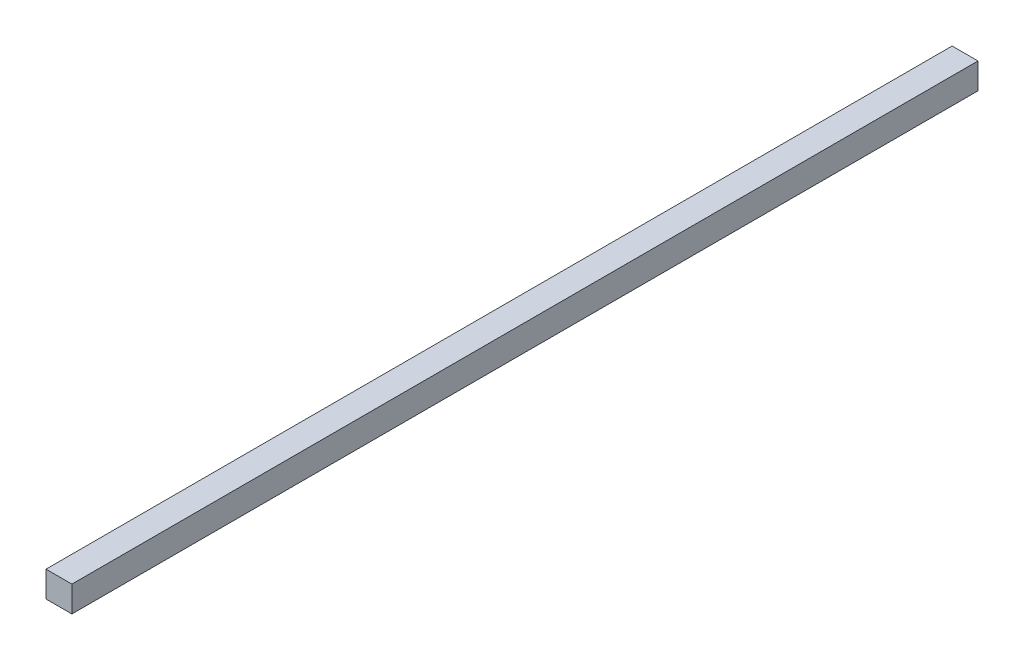
from build123d import *

# Parameters (mm, degrees)
ESQUISSE1_W        = 10
ESQUISSE1_H        = 10
BOSS_EXTRU_1_DEPTH = 350


with BuildPart() as part:
    # Esquisse1 → Boss.-Extru.1 (new body)
    with BuildSketch(Plane.XY):
        Rectangle(ESQUISSE1_W, ESQUISSE1_H)
    extrude(amount=BOSS_EXTRU_1_DEPTH)


solid = part.part
